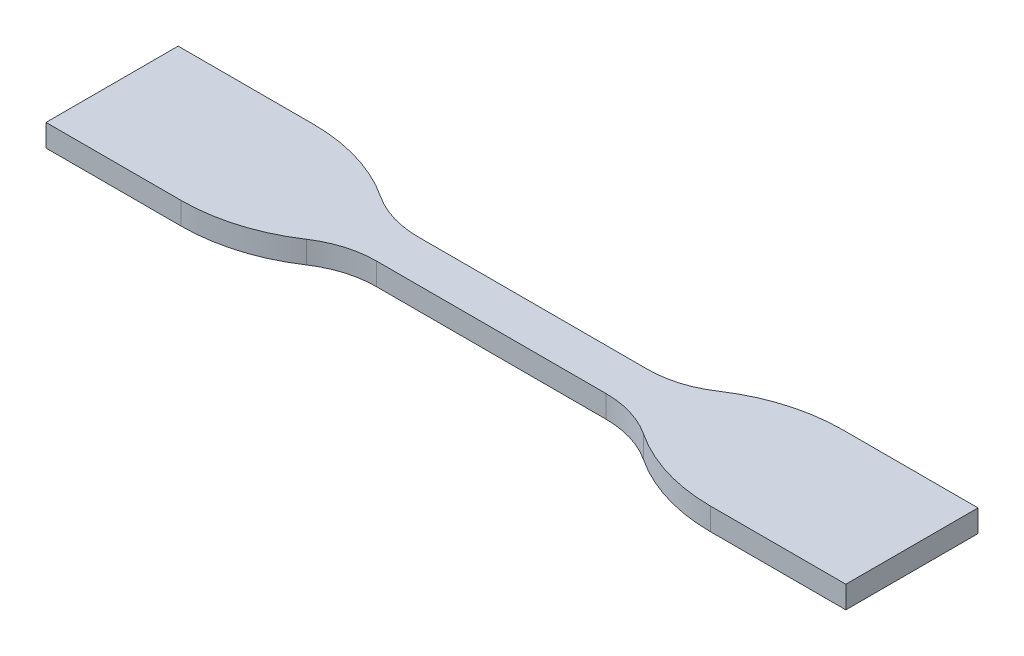
from build123d import *

# Parameters (mm, degrees)
BOSS_EXTRUDE1_DEPTH = 3.2


with BuildPart() as part:
    # Sketch1 → Boss-Extrude1 (new body)
    with BuildSketch(Plane(origin=(0, 0, 0), x_dir=(1, 0, 0), z_dir=(0, 1, 0))):
        with BuildLine():
            Line((38.058061137, -9.5), (57.5, -9.5))
            Line((57.5, -9.5), (57.5, 9.5))
            Line((57.5, 9.5), (38.058061137, 9.5))
            ThreePointArc((38.058061137, 9.5), (30.841182772, 8.435677694), (24.238791177, 5.333333333))
            ThreePointArc((24.238791177, 5.333333333), (20.541451884, 3.596020491), (16.5, 3))
            Line((16.5, 3), (-16.5, 3))
            ThreePointArc((-16.5, 3), (-20.541451884, 3.596020491), (-24.238791177, 5.333333333))
            ThreePointArc((-24.238791177, 5.333333333), (-30.841182772, 8.435677694), (-38.058061137, 9.5))
            Line((-38.058061137, 9.5), (-57.5, 9.5))
            Line((-57.5, 9.5), (-57.5, -9.5))
            Line((-57.5, -9.5), (-38.058061137, -9.5))
            ThreePointArc((-38.058061137, -9.5), (-30.841182772, -8.435677694), (-24.238791177, -5.333333333))
            ThreePointArc((-24.238791177, -5.333333333), (-20.541451884, -3.596020491), (-16.5, -3))
            Line((-16.5, -3), (16.5, -3))
            ThreePointArc((16.5, -3), (20.541451884, -3.596020491), (24.238791177, -5.333333333))
            ThreePointArc((24.238791177, -5.333333333), (30.841182772, -8.435677694), (38.058061137, -9.5))
        make_face()
    extrude(amount=BOSS_EXTRUDE1_DEPTH)


solid = part.part
